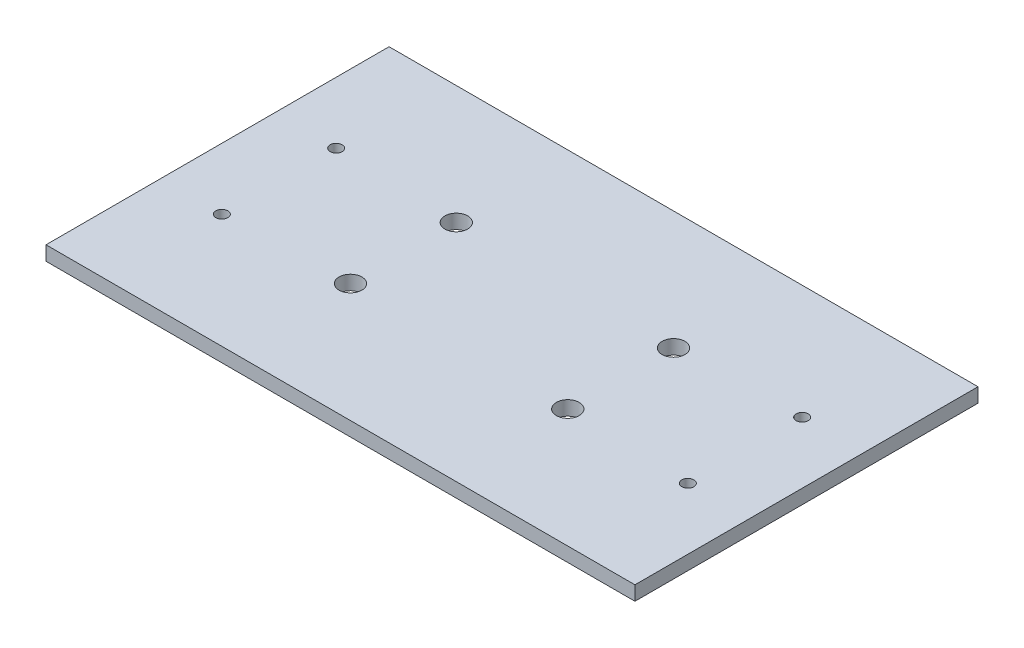
from build123d import *

# Parameters (mm, degrees)
SKETCH_1_W          = 206
SKETCH_1_H          = 120
EXTRUDE_1_DEPTH     = 5
SKETCH_2_R          = 2.1
CUT_EXTRUDE_1_DEPTH = 6
SKETCH_3_R          = 4
CUT_EXTRUDE_2_DEPTH = 6


with BuildPart() as part:
    # 草图1 → 凸台-拉伸1 (new body)
    with BuildSketch(Plane(origin=(0, 0, 0), x_dir=(1, 0, 0), z_dir=(0, 1, 0))):
        Rectangle(SKETCH_1_W, SKETCH_1_H)
    extrude(amount=EXTRUDE_1_DEPTH)

    # 草图2 → 切除-拉伸1 (cut, through all)
    with BuildSketch(Plane(origin=(0, 5, 0), x_dir=(1, 0, 0), z_dir=(0, 1, 0))):
        with Locations((-81.5, 20)):
            Circle(SKETCH_2_R)
        with Locations((81.5, 20)):
            Circle(SKETCH_2_R)
        with Locations((81.5, -20)):
            Circle(SKETCH_2_R)
        with Locations((-81.5, -20)):
            Circle(SKETCH_2_R)
    extrude(amount=-CUT_EXTRUDE_1_DEPTH, mode=Mode.SUBTRACT)

    # 草图3 → 切除-拉伸2 (cut, through all)
    with BuildSketch(Plane(origin=(0, 5, 0), x_dir=(1, 0, 0), z_dir=(0, 1, 0))):
        with Locations((-38, 18.5)):
            Circle(SKETCH_3_R)
        with Locations((38, 18.5)):
            Circle(SKETCH_3_R)
        with Locations((38, -18.5)):
            Circle(SKETCH_3_R)
        with Locations((-38, -18.5)):
            Circle(SKETCH_3_R)
    extrude(amount=-CUT_EXTRUDE_2_DEPTH, mode=Mode.SUBTRACT)


solid = part.part
